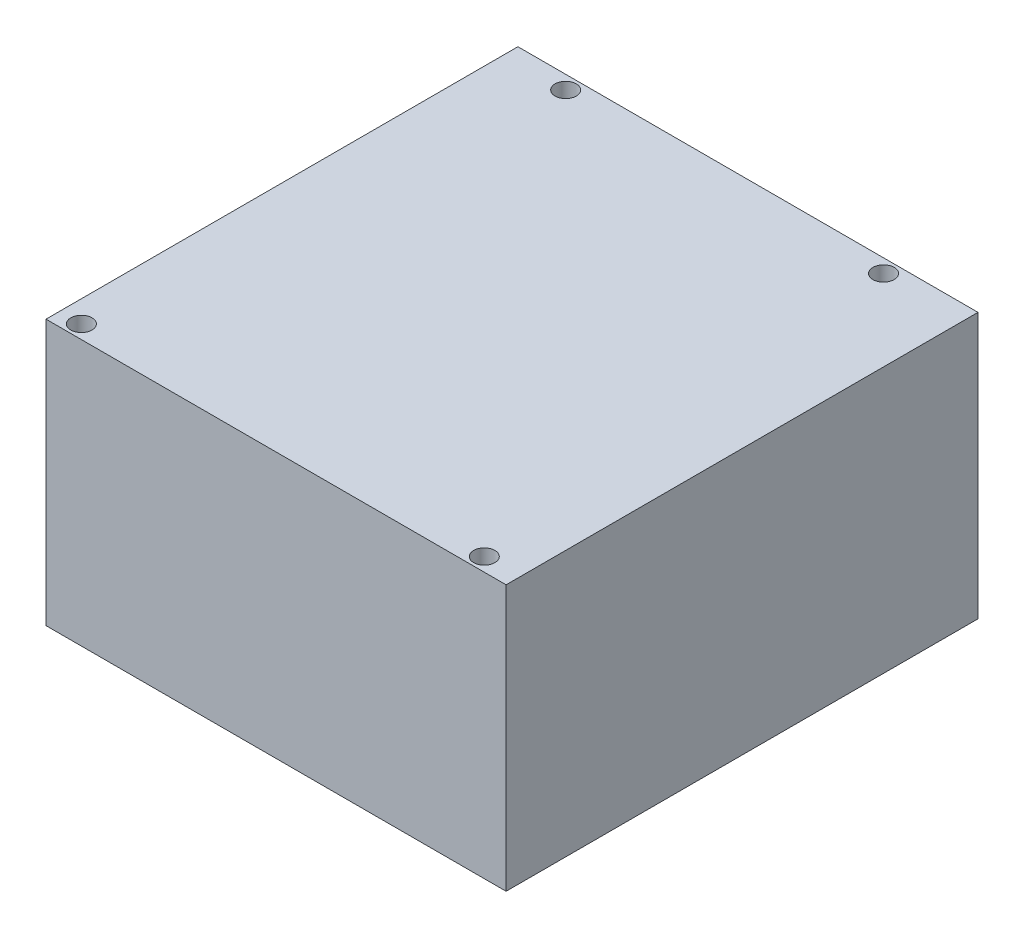
from build123d import *

# Parameters (mm, degrees)
SKETCH1_W                = 78
SKETCH1_H                = 80
BOSS_EXTRUDE1_DEPTH      = 45
M3_CLEARANCE_HOLE1_D     = 3.6
M3_CLEARANCE_HOLE1_DEPTH = 45


with BuildPart() as part:
    # Sketch1 → Boss-Extrude1 (new body)
    with BuildSketch(Plane(origin=(0, 0, 0), x_dir=(1, 0, 0), z_dir=(0, 1, 0))):
        with Locations((39, 40)):
            Rectangle(SKETCH1_W, SKETCH1_H)
    extrude(amount=BOSS_EXTRUDE1_DEPTH)

    # M3 Clearance Hole1
    with Locations(Plane(origin=(0, 45, 0), x_dir=(1, 0, 0), z_dir=(0, 1, 0))):
        with Locations((10.4, 77.7), (64.29, 77.7), (72, 2.3), (3.7, 2.3)):
            Hole(M3_CLEARANCE_HOLE1_D / 2, depth=M3_CLEARANCE_HOLE1_DEPTH)


solid = part.part
